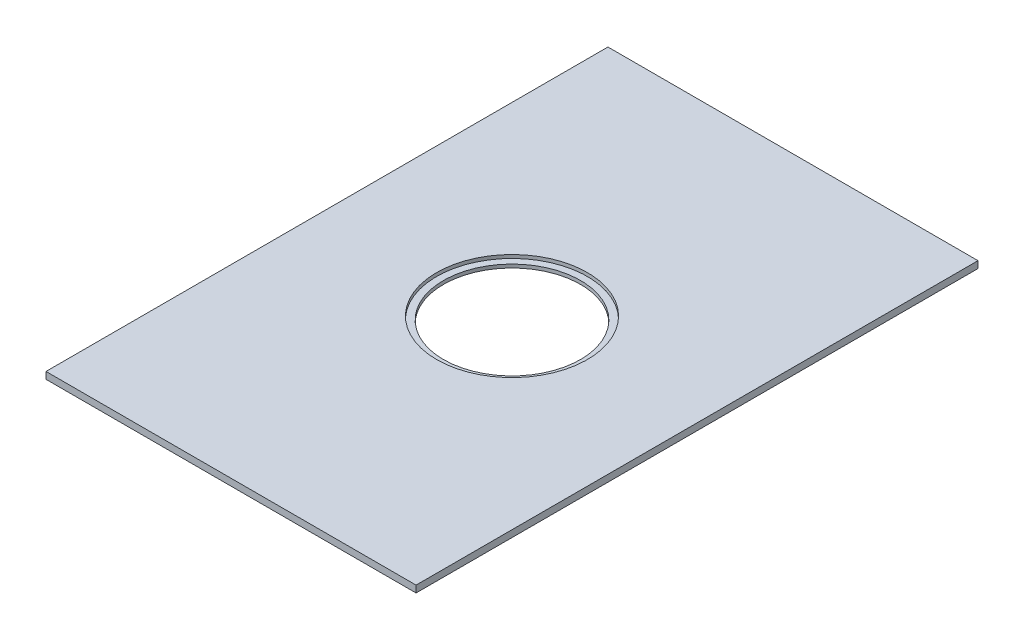
from build123d import *

# Parameters (mm, degrees)
SKETCH1_W           = 108
SKETCH1_H           = 164
BOSS_EXTRUDE1_DEPTH = 2
SKETCH2_R           = 22
CUT_EXTRUDE1_DEPTH  = 1
SKETCH3_R           = 20
CUT_EXTRUDE2_DEPTH  = 2


with BuildPart() as part:
    # Sketch1 → Boss-Extrude1 (new body)
    with BuildSketch(Plane(origin=(0, 0, 0), x_dir=(1, 0, 0), z_dir=(0, 1, 0))):
        Rectangle(SKETCH1_W, SKETCH1_H)
    extrude(amount=-BOSS_EXTRUDE1_DEPTH)

    # Sketch2 → Cut-Extrude1 (cut)
    with BuildSketch(Plane(origin=(0, 0, 0), x_dir=(1, 0, 0), z_dir=(0, 1, 0))):
        Circle(SKETCH2_R)
    extrude(amount=-CUT_EXTRUDE1_DEPTH, mode=Mode.SUBTRACT)

    # Sketch3 → Cut-Extrude2 (cut, through all)
    with BuildSketch(Plane(origin=(0, -1, 0), x_dir=(1, 0, 0), z_dir=(0, 1, 0))):
        Circle(SKETCH3_R)
    extrude(amount=-CUT_EXTRUDE2_DEPTH, mode=Mode.SUBTRACT)


solid = part.part
